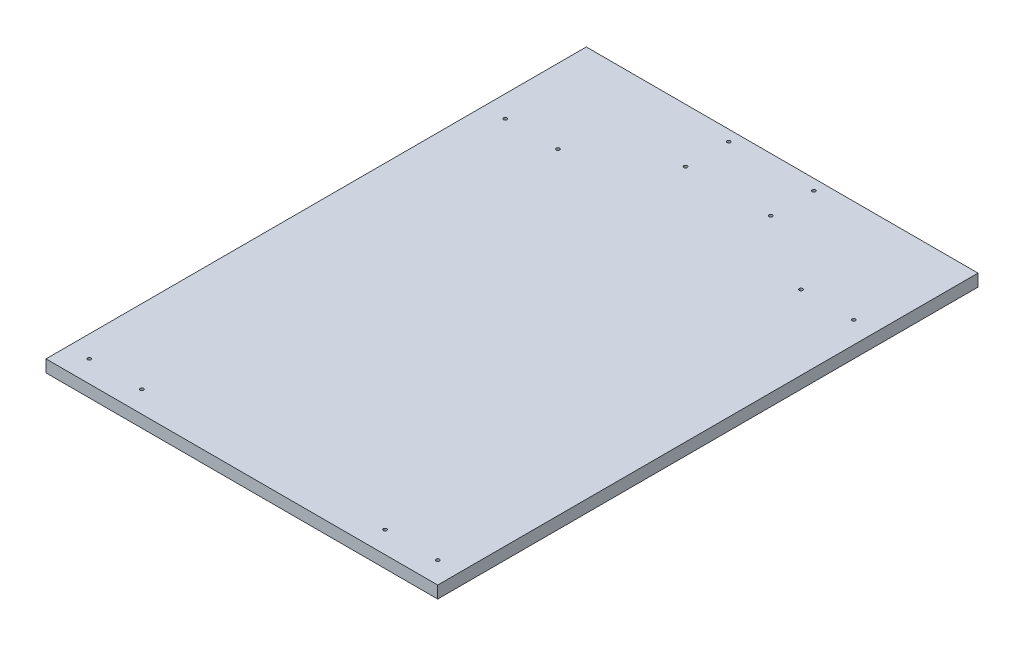
from build123d import *

# Parameters (mm, degrees)
SKETCH1_W           = 290
SKETCH1_H           = 400
BOSS_EXTRUDE1_DEPTH = 9
SKETCH2_R           = 1.25
CUT_EXTRUDE1_DEPTH  = 10


with BuildPart() as part:
    # Sketch1 → Boss-Extrude1 (new body)
    with BuildSketch(Plane(origin=(0, 0, 0), x_dir=(1, 0, 0), z_dir=(0, 1, 0))):
        with Locations((145, 200)):
            Rectangle(SKETCH1_W, SKETCH1_H)
    extrude(amount=BOSS_EXTRUDE1_DEPTH)

    # Sketch2 → Cut-Extrude1 (cut, through all)
    with BuildSketch(Plane(origin=(0, 9, 0), x_dir=(1, 0, 0), z_dir=(0, 1, 0))):
        with Locations((16, 16)):
            Circle(SKETCH2_R)
        with Locations((55, 16)):
            Circle(SKETCH2_R)
        with Locations((235, 16)):
            Circle(SKETCH2_R)
        with Locations((274, 16)):
            Circle(SKETCH2_R)
        with Locations((16, 324)):
            Circle(SKETCH2_R)
        with Locations((55, 324)):
            Circle(SKETCH2_R)
        with Locations((274, 324)):
            Circle(SKETCH2_R)
        with Locations((235, 324)):
            Circle(SKETCH2_R)
        with Locations((113.5, 392)):
            Circle(SKETCH2_R)
        with Locations((113.5, 360)):
            Circle(SKETCH2_R)
        with Locations((176.5, 360)):
            Circle(SKETCH2_R)
        with Locations((176.5, 392)):
            Circle(SKETCH2_R)
    extrude(amount=-CUT_EXTRUDE1_DEPTH, mode=Mode.SUBTRACT)


solid = part.part
